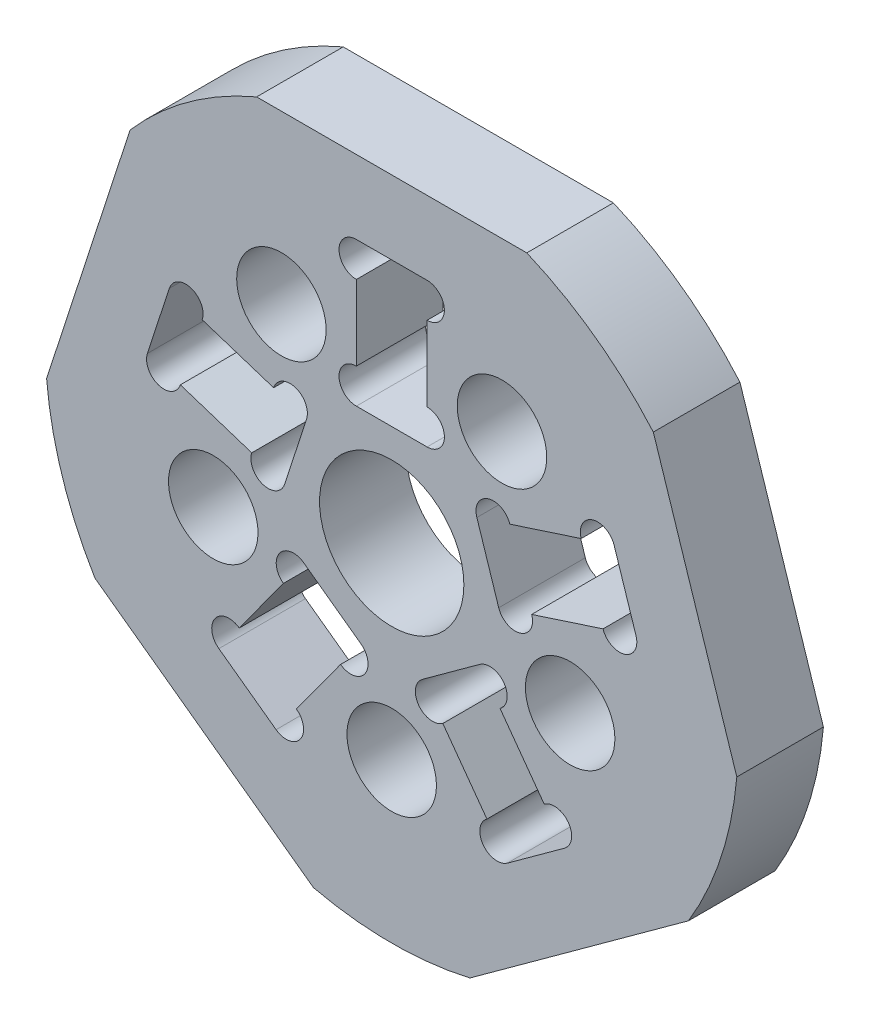
from build123d import *

# Parameters (mm, degrees)
SKETCH_1_R               = 12
EXTRUDE_1_DEPTH          = 1.5
SKETCH_2_R               = 1.55
SKETCH_2_W               = 2.45
SKETCH_2_H               = 5
CUT_EXTRUDE_1_DEPTH      = 4
PATTERN_CIRCULAR_1_COUNT = 5
SKETCH_3_R               = 0.6
CUT_EXTRUDE_2_DEPTH      = 4
PATTERN_CIRCULAR_2_COUNT = 5
SKETCH_4_R               = 2.5
CUT_EXTRUDE_3_DEPTH      = 4
CUT_EXTRUDE_4_DEPTH      = 4
PATTERN_CIRCULAR_3_COUNT = 5


with BuildPart() as part:
    # 草图1 → 凸台-拉伸1 (new body, symmetric)
    with BuildSketch(Plane.XY):
        Circle(SKETCH_1_R)
    extrude(amount=EXTRUDE_1_DEPTH, both=True)

    # 草图2 → 切除-拉伸1 (cut, through all)
    with BuildSketch(Plane.XY.offset(1.5)):
        with Locations((0, -6.5)):
            Circle(SKETCH_2_R)
        with Locations((0, 6)):
            Rectangle(SKETCH_2_W, SKETCH_2_H)
    cut_extrude_1 = extrude(amount=-CUT_EXTRUDE_1_DEPTH, mode=Mode.SUBTRACT)

    # 阵列(圆周)1: 切除-拉伸1 ×5 about axis
    pattern_circular_1_axis = Axis((0, 0, 0), (0, 0, 1))
    for i in range(1, PATTERN_CIRCULAR_1_COUNT):
        add(cut_extrude_1.rotate(pattern_circular_1_axis, i * 360 / PATTERN_CIRCULAR_1_COUNT), mode=Mode.SUBTRACT)

    # 草图3 → 切除-拉伸2 (cut, through all)
    with BuildSketch(Plane.XY.offset(1.5)):
        with Locations((1.225, 7.9)):
            Circle(SKETCH_3_R)
        with Locations((-1.225, 7.9)):
            Circle(SKETCH_3_R)
        with Locations((-1.225, 4.1)):
            Circle(SKETCH_3_R)
        with Locations((1.225, 4.1)):
            Circle(SKETCH_3_R)
    cut_extrude_2 = extrude(amount=-CUT_EXTRUDE_2_DEPTH, mode=Mode.SUBTRACT)

    # 阵列(圆周)2: 切除-拉伸2 ×5 about axis
    pattern_circular_2_axis = Axis((0, 0, 0), (0, 0, 1))
    for i in range(1, PATTERN_CIRCULAR_2_COUNT):
        add(cut_extrude_2.rotate(pattern_circular_2_axis, i * 360 / PATTERN_CIRCULAR_2_COUNT), mode=Mode.SUBTRACT)

    # 草图4 → 切除-拉伸3 (cut, through all)
    with BuildSketch(Plane.XY.offset(1.5)):
        Circle(SKETCH_4_R)
    extrude(amount=-CUT_EXTRUDE_3_DEPTH, mode=Mode.SUBTRACT)

    # 草图5 → 切除-拉伸4 (cut, through all)
    with BuildSketch(Plane.XY.offset(1.5)):
        with BuildLine():
            Line((-4.679476466, 11.05), (4.679476466, 11.05))
            ThreePointArc((4.679476466, 11.05), (0, 12), (-4.679476466, 11.05))
        make_face()
    cut_extrude_4 = extrude(amount=-CUT_EXTRUDE_4_DEPTH, mode=Mode.SUBTRACT)

    # 阵列(圆周)3: 切除-拉伸4 ×5 about axis
    pattern_circular_3_axis = Axis((0, 0, 0), (0, 0, 1))
    for i in range(1, PATTERN_CIRCULAR_3_COUNT):
        add(cut_extrude_4.rotate(pattern_circular_3_axis, i * 360 / PATTERN_CIRCULAR_3_COUNT), mode=Mode.SUBTRACT)


solid = part.part
